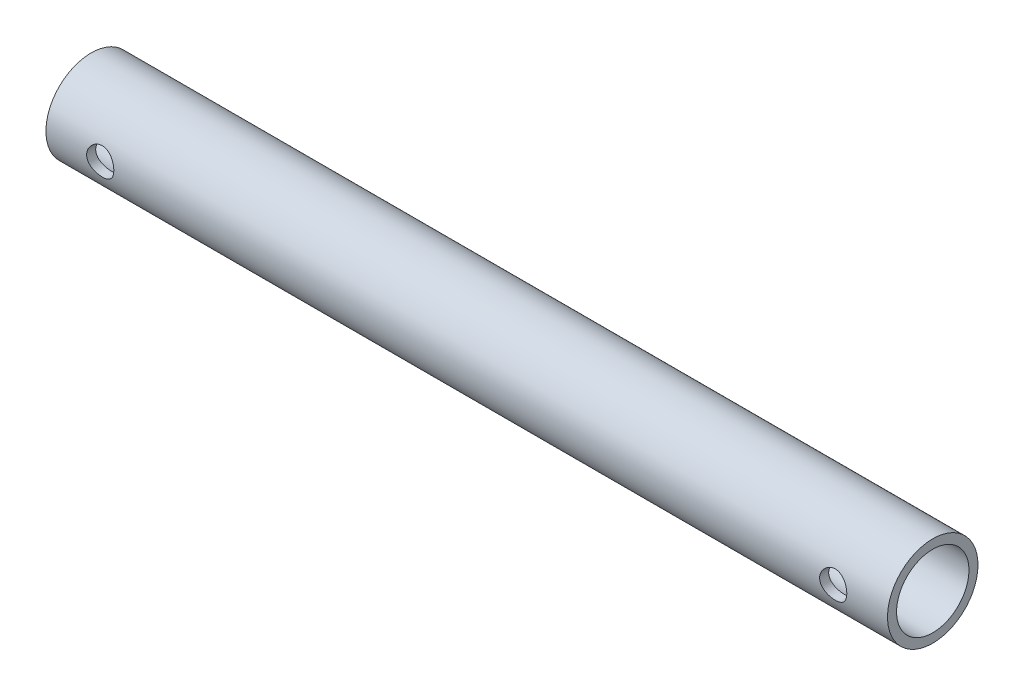
from build123d import *

# Parameters (mm, degrees)
SKETCH_1_R               = 5
SKETCH_1_R_2             = 4
EXTRUDE_1_DEPTH          = 46.5
SKETCH_2_R               = 1.5
CUT_EXTRUDE_1_DEPTH      = 6
CUT_EXTRUDE_1_DEPTH_BACK = 6


with BuildPart() as part:
    # 草图1 → 凸台-拉伸1 (new body, symmetric)
    with BuildSketch(Plane(origin=(0, 0, 0), x_dir=(0, 0, -1), z_dir=(1, 0, 0))):
        Circle(SKETCH_1_R)
        Circle(SKETCH_1_R_2, mode=Mode.SUBTRACT)
    extrude(amount=EXTRUDE_1_DEPTH, both=True)

    # 草图2 → 切除-拉伸1 (cut, two sides)
    with BuildSketch(Plane.XY) as cut_extrude_1_sk:
        with Locations((40.5, 0)):
            Circle(SKETCH_2_R)
        with Locations((-40.5, 0)):
            Circle(SKETCH_2_R)
    extrude(amount=CUT_EXTRUDE_1_DEPTH, mode=Mode.SUBTRACT)
    extrude(cut_extrude_1_sk.sketch, amount=-CUT_EXTRUDE_1_DEPTH_BACK, mode=Mode.SUBTRACT)


solid = part.part
